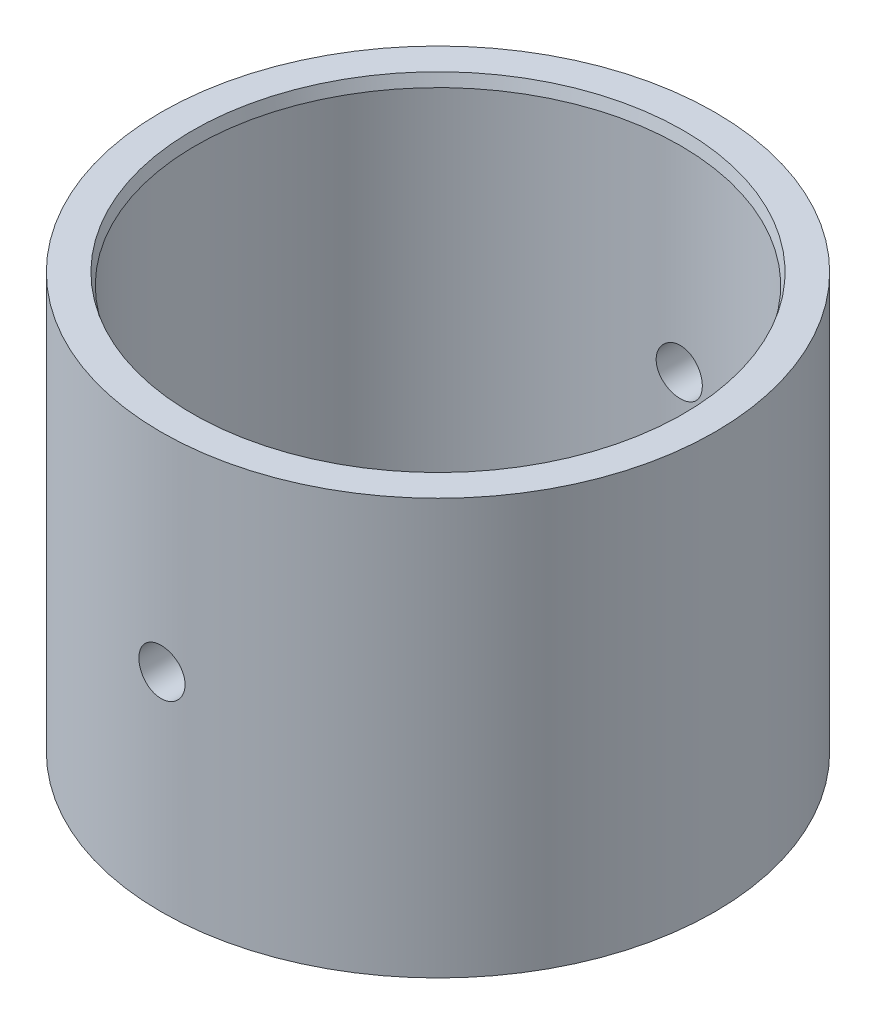
from build123d import *

# Parameters (mm, degrees)
ESQUISSE2_R                  = 2
ENL_V_MAT_EXTRU_1_DEPTH      = 25
ENL_V_MAT_EXTRU_1_DEPTH_BACK = 25


with BuildPart() as part:
    # Esquisse1 → Révolution1 (revolve)
    with BuildSketch(Plane.XY, mode=Mode.PRIVATE) as r_volution1_sk:
        Polygon((-24, 36), (-21.267949192, 36), (-21, 35), (-21, 1), (-21.267949192, 0), (-24, 0), align=None)
    revolve(r_volution1_sk.sketch.rotate(Axis((0, 0, 0), (0, 1, 0)), 270), axis=Axis((0, 0, 0), (0, 1, 0)))  # turned: the seam where the file's is

    # Esquisse2 → Enlèv. mat.-Extru.1 (cut, two sides)
    with BuildSketch(Plane.XY) as enl_v_mat_extru_1_sk:
        with Locations((0, 18)):
            Circle(ESQUISSE2_R)
    extrude(amount=ENL_V_MAT_EXTRU_1_DEPTH, mode=Mode.SUBTRACT)
    extrude(enl_v_mat_extru_1_sk.sketch, amount=-ENL_V_MAT_EXTRU_1_DEPTH_BACK, mode=Mode.SUBTRACT)


solid = part.part
